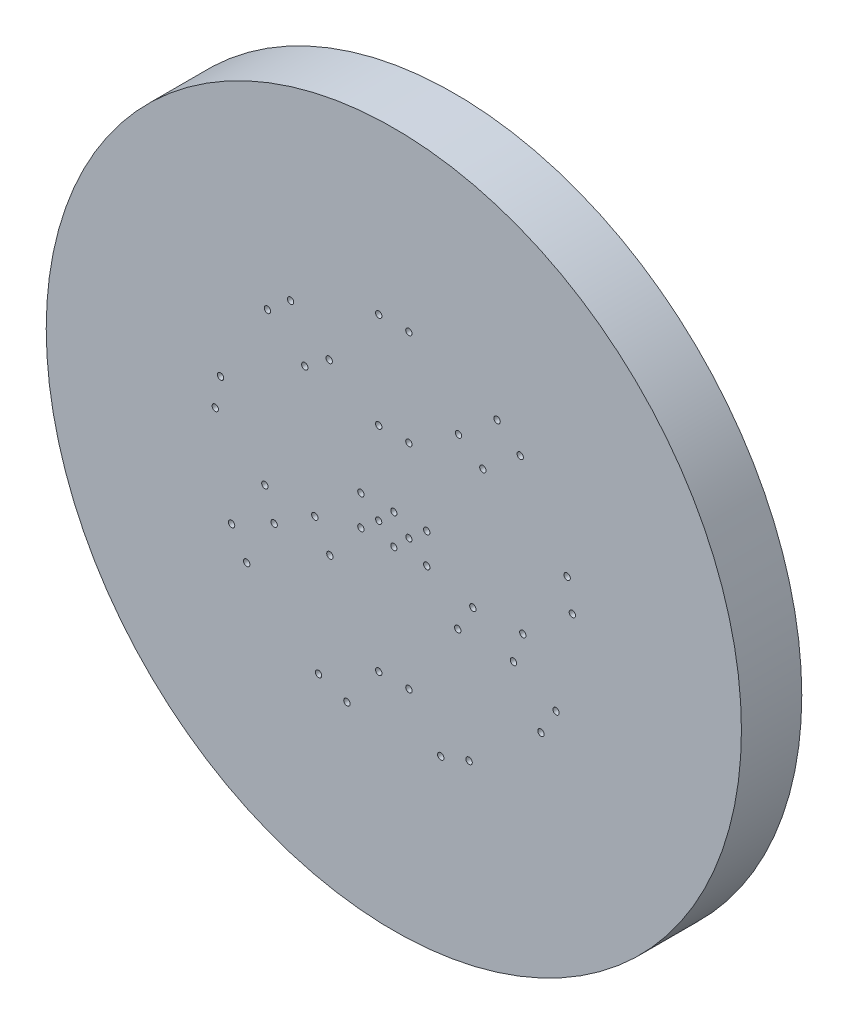
from build123d import *

# Parameters (mm, degrees)
SCHIZZO1_R                   = 28.8
ESTRUSIONE_ESTRUSIONE1_DEPTH = 5
SCHIZZO2_R                   = 0.2635
TAGLIO_ESTRUSIONE1_DEPTH     = 6
RIPETIZIONECIRCOLARE1_COUNT  = 9
SCHIZZO6_R                   = 0.2635
TAGLIO_ESTRUSIONE2_DEPTH     = 6
RIPETIZIONECIRCOLARE2_COUNT  = 5
SCHIZZO7_R                   = 0.2635
TAGLIO_ESTRUSIONE3_DEPTH     = 6
RIPETIZIONECIRCOLARE3_COUNT  = 3
SCHIZZO8_R                   = 0.2635
TAGLIO_ESTRUSIONE4_DEPTH     = 6
RIPETIZIONECIRCOLARE4_COUNT  = 2
SCHIZZO9_R                   = 0.2545
TAGLIO_ESTRUSIONE5_DEPTH     = 6


with BuildPart() as part:
    # Schizzo1 → Estrusione-Estrusione1 (new body)
    with BuildSketch(Plane.XY):
        Circle(SCHIZZO1_R)
    extrude(amount=ESTRUSIONE_ESTRUSIONE1_DEPTH)

    # Schizzo2 → Taglio-Estrusione1 (cut, through all)
    with BuildSketch(Plane.XY.offset(5)):
        with Locations((-1.25, 14.79729705)):
            Circle(SCHIZZO2_R)
        with Locations((1.25, 14.79729705)):
            Circle(SCHIZZO2_R)
    taglio_estrusione1 = extrude(amount=-TAGLIO_ESTRUSIONE1_DEPTH, mode=Mode.SUBTRACT)

    # RipetizioneCircolare1: Taglio-Estrusione1 ×9 about axis
    ripetizionecircolare1_axis = Axis((0, -0.002477772, 0), (0, 0, 1))
    for i in range(1, RIPETIZIONECIRCOLARE1_COUNT):
        add(taglio_estrusione1.rotate(ripetizionecircolare1_axis, i * 360 / RIPETIZIONECIRCOLARE1_COUNT), mode=Mode.SUBTRACT)

    # Schizzo6 → Taglio-Estrusione2 (cut, through all)
    with BuildSketch(Plane.XY.offset(5)):
        with Locations((-1.25, -10.828088474)):
            Circle(SCHIZZO6_R)
        with Locations((1.25, -10.828088474)):
            Circle(SCHIZZO6_R)
    taglio_estrusione2 = extrude(amount=-TAGLIO_ESTRUSIONE2_DEPTH, mode=Mode.SUBTRACT)

    # RipetizioneCircolare2: Taglio-Estrusione2 ×5 about axis
    ripetizionecircolare2_axis = Axis((0, 0.001819614, 0), (0, 0, 1))
    for i in range(1, RIPETIZIONECIRCOLARE2_COUNT):
        add(taglio_estrusione2.rotate(ripetizionecircolare2_axis, i * 360 / RIPETIZIONECIRCOLARE2_COUNT), mode=Mode.SUBTRACT)

    # Schizzo7 → Taglio-Estrusione3 (cut, through all)
    with BuildSketch(Plane.XY.offset(5)):
        with Locations((-1.25, 6.836665854)):
            Circle(SCHIZZO7_R)
        with Locations((1.25, 6.836665854)):
            Circle(SCHIZZO7_R)
    taglio_estrusione3 = extrude(amount=-TAGLIO_ESTRUSIONE3_DEPTH, mode=Mode.SUBTRACT)

    # RipetizioneCircolare3: Taglio-Estrusione3 ×3 about axis
    ripetizionecircolare3_axis = Axis((0, -0.001145258, 0), (0, 0, 1))
    for i in range(1, RIPETIZIONECIRCOLARE3_COUNT):
        add(taglio_estrusione3.rotate(ripetizionecircolare3_axis, i * 360 / RIPETIZIONECIRCOLARE3_COUNT), mode=Mode.SUBTRACT)

    # Schizzo8 → Taglio-Estrusione4 (cut, through all)
    with BuildSketch(Plane.XY.offset(5)):
        with Locations((2.727178029, 1.25)):
            Circle(SCHIZZO8_R)
        with Locations((2.727178029, -1.25)):
            Circle(SCHIZZO8_R)
    taglio_estrusione4 = extrude(amount=-TAGLIO_ESTRUSIONE4_DEPTH, mode=Mode.SUBTRACT)

    # RipetizioneCircolare4: Taglio-Estrusione4 ×2 about axis
    ripetizionecircolare4_axis = Axis((-0.000457963, 2.794e-06, 0), (0, 0, 1))
    for i in range(1, RIPETIZIONECIRCOLARE4_COUNT):
        add(taglio_estrusione4.rotate(ripetizionecircolare4_axis, i * 360 / RIPETIZIONECIRCOLARE4_COUNT), mode=Mode.SUBTRACT)

    # Schizzo9 → Taglio-Estrusione5 (cut, through all)
    with BuildSketch(Plane.XY.offset(5)):
        with Locations((-1.25, 0)):
            Circle(SCHIZZO9_R)
        with Locations((1.25, 0)):
            Circle(SCHIZZO9_R)
        with Locations((0, -1.25)):
            Circle(SCHIZZO9_R)
        with Locations((0, 1.25)):
            Circle(SCHIZZO9_R)
    extrude(amount=-TAGLIO_ESTRUSIONE5_DEPTH, mode=Mode.SUBTRACT)


solid = part.part
